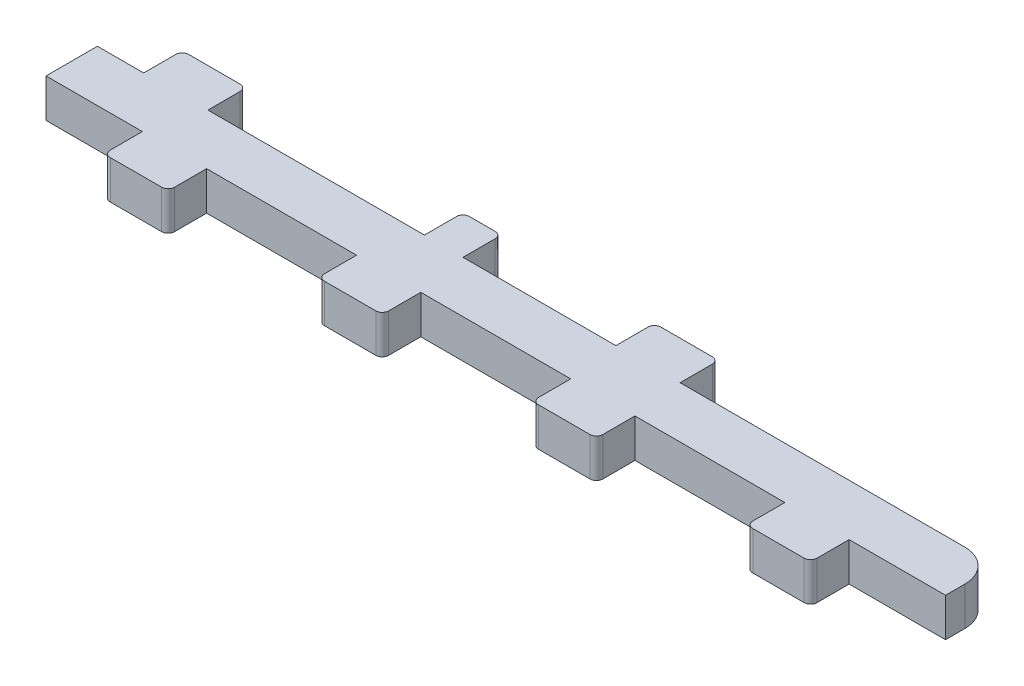
from build123d import *

# Parameters (mm, degrees)
SKETCH1_W               = 140
SKETCH1_H               = 8
BOSS_EXTRUDE1_DEPTH     = 6
SKETCH234_W             = 10
SKETCH234_H             = 6
BOSS_EXTRUDE234_DEPTH   = 6
FILLET134_R             = 1
SKETCH2341_W            = 10
SKETCH2341_H            = 6
BOSS_EXTRUDE2341_DEPTH  = 6
FILLET1341_R            = 1
SKETCH2342_W            = 10
SKETCH2342_H            = 6
BOSS_EXTRUDE2342_DEPTH  = 6
FILLET1342_R            = 1
SKETCH2343_W            = 10
SKETCH2343_H            = 6
BOSS_EXTRUDE2343_DEPTH  = 6
FILLET1343_R            = 1
SKETCH2344_W            = 10
SKETCH2344_H            = 6
BOSS_EXTRUDE2344_DEPTH  = 6
FILLET1344_R            = 1
SKETCH2346_W            = 10
SKETCH2346_H            = 6
BOSS_EXTRUDE2346_DEPTH  = 6
FILLET1346_R            = 1
FILLET1347_R            = 5
SKETCH23410_W           = 6
SKETCH23410_H           = 6
BOSS_EXTRUDE23410_DEPTH = 6
FILLET13411_R           = 1


with BuildPart() as part:
    # Sketch1 → Boss-Extrude1 (new body)
    with BuildSketch(Plane(origin=(0, 0, 0), x_dir=(1, 0, 0), z_dir=(0, 1, 0))):
        with Locations((70, 4)):
            Rectangle(SKETCH1_W, SKETCH1_H)
    extrude(amount=BOSS_EXTRUDE1_DEPTH)

    # Sketch234 → Boss-Extrude234 (add)
    with BuildSketch(Plane(origin=(119.232221392, 0, 0), x_dir=(1, 0, 0), z_dir=(0, 0, 1))):
        with Locations((0.767778608, 3)):
            Rectangle(SKETCH234_W, SKETCH234_H)
    extrude(amount=BOSS_EXTRUDE234_DEPTH)

    # Fillet134
    fillet134_edges = [part.edges().sort_by_distance(p)[0] for p in [
        (115, 3, 6),
        (125, 3, 6),
    ]]
    fillet(fillet134_edges, radius=FILLET134_R)

    # Sketch2341 → Boss-Extrude2341 (add)
    with BuildSketch(Plane(origin=(85.898888059, 0, 0), x_dir=(1, 0, 0), z_dir=(0, 0, 1))):
        with Locations((0.767778608, 3)):
            Rectangle(SKETCH2341_W, SKETCH2341_H)
    extrude(amount=BOSS_EXTRUDE2341_DEPTH)

    # Fillet1341
    fillet1341_edges = [part.edges().sort_by_distance(p)[0] for p in [
        (91.666666667, 3, 6),
        (81.666666667, 3, 6),
    ]]
    fillet(fillet1341_edges, radius=FILLET1341_R)

    # Sketch2342 → Boss-Extrude2342 (add)
    with BuildSketch(Plane(origin=(52.565554726, 0, 0), x_dir=(1, 0, 0), z_dir=(0, 0, 1))):
        with Locations((0.767778608, 3)):
            Rectangle(SKETCH2342_W, SKETCH2342_H)
    extrude(amount=BOSS_EXTRUDE2342_DEPTH)

    # Fillet1342
    fillet1342_edges = [part.edges().sort_by_distance(p)[0] for p in [
        (58.333333333, 3, 6),
        (48.333333333, 3, 6),
    ]]
    fillet(fillet1342_edges, radius=FILLET1342_R)

    # Sketch2343 → Boss-Extrude2343 (add)
    with BuildSketch(Plane(origin=(19.232221392, 0, 0), x_dir=(1, 0, 0), z_dir=(0, 0, 1))):
        with Locations((0.767778608, 3)):
            Rectangle(SKETCH2343_W, SKETCH2343_H)
    extrude(amount=BOSS_EXTRUDE2343_DEPTH)

    # Fillet1343
    fillet1343_edges = [part.edges().sort_by_distance(p)[0] for p in [
        (25, 3, 6),
        (15, 3, 6),
    ]]
    fillet(fillet1343_edges, radius=FILLET1343_R)

    # Sketch2344 → Boss-Extrude2344 (add)
    with BuildSketch(Plane(origin=(84.932221392, 6, -8), x_dir=(1, 0, 0), z_dir=(0, 0, -1))):
        with Locations((0.767778608, 3)):
            Rectangle(SKETCH2344_W, SKETCH2344_H)
    extrude(amount=BOSS_EXTRUDE2344_DEPTH)

    # Fillet1344
    fillet1344_edges = [part.edges().sort_by_distance(p)[0] for p in [
        (80.7, 3, -14),
        (90.7, 3, -14),
    ]]
    fillet(fillet1344_edges, radius=FILLET1344_R)

    # Sketch2346 → Boss-Extrude2346 (add)
    with BuildSketch(Plane(origin=(11.432221392, 6, -8), x_dir=(1, 0, 0), z_dir=(0, 0, -1))):
        with Locations((0.767778608, 3)):
            Rectangle(SKETCH2346_W, SKETCH2346_H)
    extrude(amount=BOSS_EXTRUDE2346_DEPTH)

    # Fillet1346
    fillet1346_edges = [part.edges().sort_by_distance(p)[0] for p in [
        (17.2, 3, -14),
        (7.2, 3, -14),
    ]]
    fillet(fillet1346_edges, radius=FILLET1346_R)

    # Fillet1347
    fillet1347_edges = [part.edges().sort_by_distance(p)[0] for p in [
        (140, 3, -8),
    ]]
    fillet(fillet1347_edges, radius=FILLET1347_R)

    # Sketch23410 → Boss-Extrude23410 (add)
    with BuildSketch(Plane(origin=(53.132221392, 6, -8), x_dir=(1, 0, 0), z_dir=(0, 0, -1))):
        with Locations((0.767778608, 3)):
            Rectangle(SKETCH23410_W, SKETCH23410_H)
    extrude(amount=BOSS_EXTRUDE23410_DEPTH)

    # Fillet13411
    fillet13411_edges = [part.edges().sort_by_distance(p)[0] for p in [
        (56.9, 3, -14),
        (50.9, 3, -14),
    ]]
    fillet(fillet13411_edges, radius=FILLET13411_R)


solid = part.part
